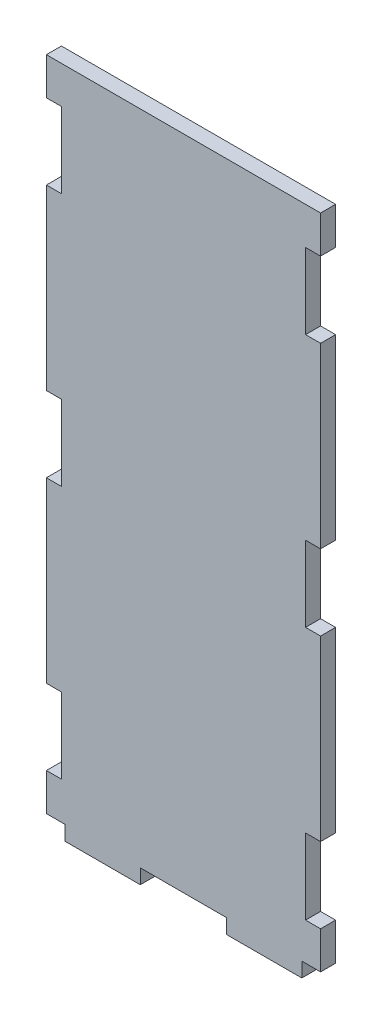
from build123d import *

# Parameters (mm, degrees)
EXTRUDE_1_DEPTH = 4


with BuildPart() as part:
    # ｽｹｯﾁ1 → ﾎﾞｽ - 押し出し1 (new body)
    with BuildSketch(Plane(origin=(0, 0, 0), x_dir=(0, 1, 0), z_dir=(0, 0, 1))):
        Polygon((-3.9, 25), (-3.9, 5), (0, 5), (0, 0), (9.95, 0), (9.95, 4), (30.05, 4), (30.05, 0), (77.45, 0), (77.45, 4), (97.55, 4), (97.55, 0), (144.95, 0), (144.95, 4), (165.05, 4), (165.05, 0), (175, 0), (175, 73), (165.05, 73), (165.05, 69), (144.95, 69), (144.95, 73), (97.55, 73), (97.55, 69), (77.45, 69), (77.45, 73), (30.05, 73), (30.05, 69), (9.95, 69), (9.95, 73), (0, 73), (0, 68), (-3.9, 68), (-3.9, 48), (0, 48), (0, 25), align=None)
    extrude(amount=EXTRUDE_1_DEPTH)


solid = part.part
